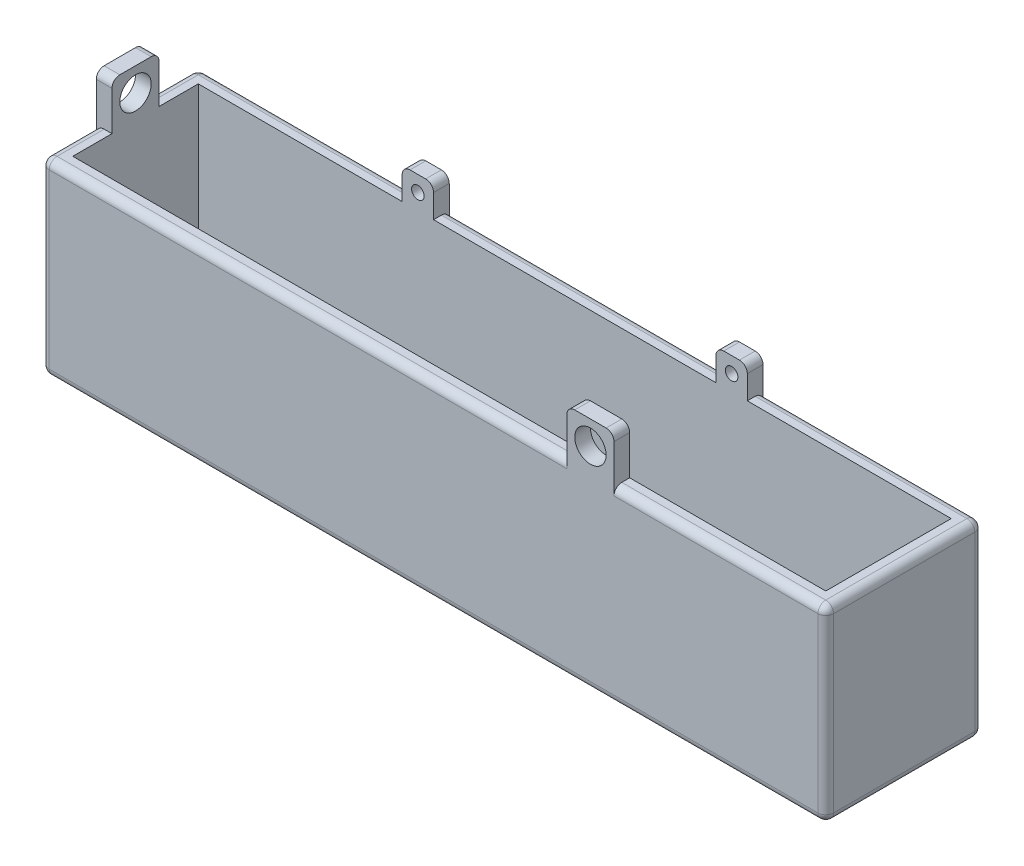
from build123d import *

# Parameters (mm, degrees)
SKETCH1_W           = 240
SKETCH1_H           = 50
BOSS_EXTRUDE1_DEPTH = 25
SKETCH1_5_W         = 240
SKETCH1_5_H         = 50
CUT_EXTRUDE1_DEPTH  = 20
BOSS_EXTRUDE3_START = -25
SKETCH1_6_W         = 10
SKETCH1_6_H         = 10
SKETCH1_6_R         = 2
BOSS_EXTRUDE3_DEPTH = 5
BOSS_EXTRUDE4_START = 25
BOSS_EXTRUDE4_DEPTH = 5
SKETCH2_W           = 15
SKETCH2_H           = 15
SKETCH2_R           = 5
BOSS_EXTRUDE5_DEPTH = 5
FILLET1_R           = 2.5


with BuildPart() as part:
    # Sketch1 → Boss-Extrude1 (new, symmetric)
    with BuildSketch(Plane.XY):
        Polygon((-125, 30), (-125, -30), (125, -30), (125, 30), (120, 30), (120, 25), (120, -25), (-120, -25), (-120, 25), (-120, 30), align=None)
        Rectangle(SKETCH1_W, SKETCH1_H)
        Polygon((-55, 30), (-120, 30), (-120, 25), (120, 25), (120, 30), (57.5, 30), (55, 30), (45, 30), (42.5, 30), (-45, 30), align=None)
    extrude(amount=BOSS_EXTRUDE1_DEPTH, both=True)

    # Sketch1_5 → Cut-Extrude1 (cut, symmetric)
    with BuildSketch(Plane.XY):
        Rectangle(SKETCH1_5_W, SKETCH1_5_H)
        Polygon((-55, 30), (-120, 30), (-120, 25), (120, 25), (120, 30), (57.5, 30), (55, 30), (45, 30), (42.5, 30), (-45, 30), align=None)
    extrude(amount=CUT_EXTRUDE1_DEPTH, both=True, mode=Mode.SUBTRACT)

    # Sketch1_6 → Boss-Extrude3 (add)
    with BuildSketch(Plane.XY.offset(BOSS_EXTRUDE3_START)):
        with Locations((-50, 35)):
            Rectangle(SKETCH1_6_W, SKETCH1_6_H)
        with Locations((-50, 35)):
            Circle(SKETCH1_6_R, mode=Mode.SUBTRACT)
        with Locations((50, 35)):
            Rectangle(SKETCH1_6_W, SKETCH1_6_H)
        with Locations((50, 35)):
            Circle(SKETCH1_6_R, mode=Mode.SUBTRACT)
    extrude(amount=BOSS_EXTRUDE3_DEPTH)

    # Sketch1_8 → Boss-Extrude4 (add)
    with BuildSketch(Plane.XY.offset(BOSS_EXTRUDE4_START)):
        with BuildLine():
            Line((45, 30), (55, 30))
            Line((55, 30), (55, 37.5))
            ThreePointArc((55, 37.5), (50, 32.5), (45, 37.5))
            Line((45, 37.5), (45, 30))
        make_face()
        with BuildLine():
            Line((55, 30), (57.5, 30))
            Line((57.5, 30), (57.5, 45))
            Line((57.5, 45), (42.5, 45))
            Line((42.5, 45), (42.5, 30))
            Line((42.5, 30), (45, 30))
            Line((45, 30), (45, 37.5))
            Line((45, 37.5), (45, 40))
            Line((45, 40), (45.669872981, 40))
            ThreePointArc((45.669872981, 40), (50, 42.5), (54.330127019, 40))
            Line((54.330127019, 40), (55, 40))
            Line((55, 40), (55, 37.5))
            Line((55, 37.5), (55, 30))
        make_face()
        with BuildLine():
            Line((45, 40), (45, 37.5))
            ThreePointArc((45, 37.5), (45.170370869, 38.794095226), (45.669872981, 40))
            Line((45.669872981, 40), (45, 40))
        make_face()
        with BuildLine():
            ThreePointArc((54.330127019, 40), (54.829629131, 38.794095226), (55, 37.5))
            Line((55, 37.5), (55, 40))
            Line((55, 40), (54.330127019, 40))
        make_face()
    extrude(amount=-BOSS_EXTRUDE4_DEPTH)

    # Sketch2 → Boss-Extrude5 (add)
    with BuildSketch(Plane.ZY.offset(125)):
        with Locations((0, 37.5)):
            Rectangle(SKETCH2_W, SKETCH2_H)
        with Locations((0, 37.5)):
            Circle(SKETCH2_R, mode=Mode.SUBTRACT)
    extrude(amount=-BOSS_EXTRUDE5_DEPTH)

    # Fillet1
    fillet1_edges = [part.edges().sort_by_distance(p)[0] for p in [
        (-41.25, 30, 25),
        (125, 30, 0),
        (-125, 0, 25),
        (0, -30, 25),
        (0, 30, -25),
        (-45, 40, -22.5),
        (-55, 40, -22.5),
        (90, 30, -25),
        (55, 40, -22.5),
        (125, 0, 25),
        (45, 40, -22.5),
        (0, -30, -25),
        (91.25, 30, 25),
        (-125, 0, -25),
        (57.5, 45, 22.5),
        (42.5, 45, 22.5),
        (-90, 30, -25),
        (125, 0, -25),
        (-125, 30, -16.25),
        (-122.5, 45, 7.5),
        (-122.5, 45, -7.5),
        (125, -30, 0),
        (-125, -30, 0),
        (-125, 30, 16.25),
    ]]
    fillet(fillet1_edges, radius=FILLET1_R)


solid = part.part
